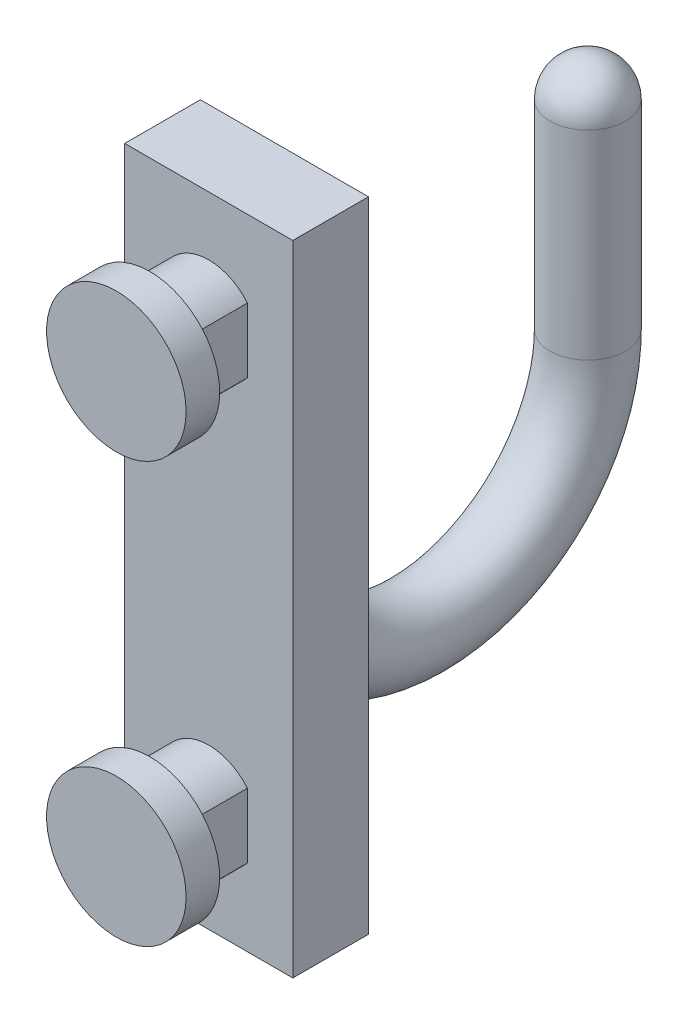
from build123d import *

# Parameters (mm, degrees)
EXTRUDE_1_DEPTH   = 3.5
EXTRUDE_1_2_DEPTH = 3.5
SKETCH_2_R        = 4.15
EXTRUDE_2_DEPTH   = 2
SKETCH_3_W        = 10
SKETCH_3_H        = 38
EXTRUDE_3_DEPTH   = 4.5
SKETCH_5_R        = 2.25


with BuildPart() as part:
    # 草图1 → 凸台-拉伸1 (new body)
    with BuildSketch(Plane.XY):
        with BuildLine():
            Line((-2.3, 1.926136028), (-2.3, -1.926136028))
            ThreePointArc((-2.3, -1.926136028), (0, -3), (2.3, -1.926136028))
            Line((2.3, -1.926136028), (2.3, 1.926136028))
            ThreePointArc((2.3, 1.926136028), (0, 3), (-2.3, 1.926136028))
        make_face()
    extrude(amount=EXTRUDE_1_DEPTH)



with BuildPart() as body_2:
    # 草图1 → Extrude 1 2 (new body)
    with BuildSketch(Plane.XY):
        with BuildLine():
            Line((-2.3, -23.073863972), (-2.3, -26.926136028))
            ThreePointArc((-2.3, -26.926136028), (0, -28), (2.3, -26.926136028))
            Line((2.3, -26.926136028), (2.3, -23.073863972))
            ThreePointArc((2.3, -23.073863972), (0, -22), (-2.3, -23.073863972))
        make_face()
    extrude(amount=EXTRUDE_1_2_DEPTH)


with BuildPart() as part_1:
    add(part.part)

    add(body_2.part)  # 凸台-拉伸2 merges body 2
    # 草图2 → 凸台-拉伸2 (add)
    with BuildSketch(Plane.XY.offset(3.5)):
        Circle(SKETCH_2_R)
        with Locations((0, -25)):
            Circle(SKETCH_2_R)
    extrude(amount=EXTRUDE_2_DEPTH)

    # 草图3 → 凸台-拉伸3 (add)
    with BuildSketch(Plane(origin=(0, 0, 0), x_dir=(-1, 0, 0), z_dir=(0, 0, -1))):
        with Locations((0, -12.5)):
            Rectangle(SKETCH_3_W, SKETCH_3_H)
    extrude(amount=EXTRUDE_3_DEPTH)

    # 扫描1: sweep along a path in 草图4
    with BuildLine(Plane(origin=(0, 0, 0), x_dir=(0, 0, -1), z_dir=(1, 0, 0))) as sweep_1_path:
        Line((2.25, 0), (2.25, -11.85))
        ThreePointArc((2.25, -11.85), (12.4, -22), (22.55, -11.85))
        Line((22.55, -11.85), (22.55, 0))
    # 草图5 → 扫描1 (sweep)
    with BuildSketch(Plane(origin=(0, 0, 0), x_dir=(1, 0, 0), z_dir=(0, 1, 0))):
        with Locations((0, 22.55)):
            Circle(SKETCH_5_R)
    sweep(path=sweep_1_path.line)

    # 草图6 → 旋转1 (revolve)
    with BuildSketch(Plane(origin=(0, 0, 0), x_dir=(0, 0, -1), z_dir=(1, 0, 0))):
        with BuildLine():
            Line((22.55, 0), (22.55, 2.25))
            ThreePointArc((22.55, 2.25), (20.959009742, 1.590990258), (20.3, 0))
            Line((20.3, 0), (22.55, 0))
        make_face()
    revolve(axis=Axis((0, 0, -22.55), (0, 1, 0)))


solid = part_1.part
